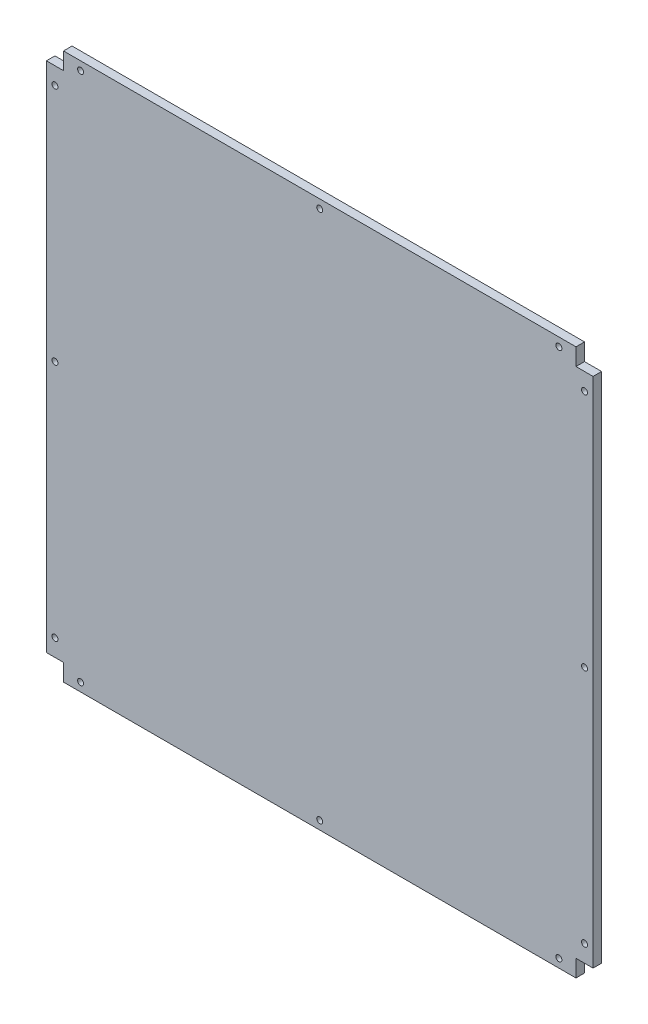
from build123d import *

# Parameters (mm, degrees)
SKETCH1_R           = 1.75
BOSS_EXTRUDE1_DEPTH = 5


with BuildPart() as part:
    # Sketch1 → Boss-Extrude1 (new body)
    with BuildSketch(Plane.XY):
        Polygon((0, 0), (0, 10), (300, 10), (300, 0), (310, 0), (310, -300), (300, -300), (300, -310), (0, -310), (0, -300), (-10, -300), (-10, 0), align=None)
        with Locations((10, 5)):
            Circle(SKETCH1_R, mode=Mode.SUBTRACT)
        with Locations((150, 5)):
            Circle(SKETCH1_R, mode=Mode.SUBTRACT)
        with Locations((290, 5)):
            Circle(SKETCH1_R, mode=Mode.SUBTRACT)
        with Locations((-5, -290)):
            Circle(SKETCH1_R, mode=Mode.SUBTRACT)
        with Locations((-5, -150)):
            Circle(SKETCH1_R, mode=Mode.SUBTRACT)
        with Locations((-5, -10)):
            Circle(SKETCH1_R, mode=Mode.SUBTRACT)
        with Locations((290, -305)):
            Circle(SKETCH1_R, mode=Mode.SUBTRACT)
        with Locations((150, -305)):
            Circle(SKETCH1_R, mode=Mode.SUBTRACT)
        with Locations((10, -305)):
            Circle(SKETCH1_R, mode=Mode.SUBTRACT)
        with Locations((305, -10)):
            Circle(SKETCH1_R, mode=Mode.SUBTRACT)
        with Locations((305, -150)):
            Circle(SKETCH1_R, mode=Mode.SUBTRACT)
        with Locations((305, -290)):
            Circle(SKETCH1_R, mode=Mode.SUBTRACT)
    extrude(amount=BOSS_EXTRUDE1_DEPTH)


solid = part.part
